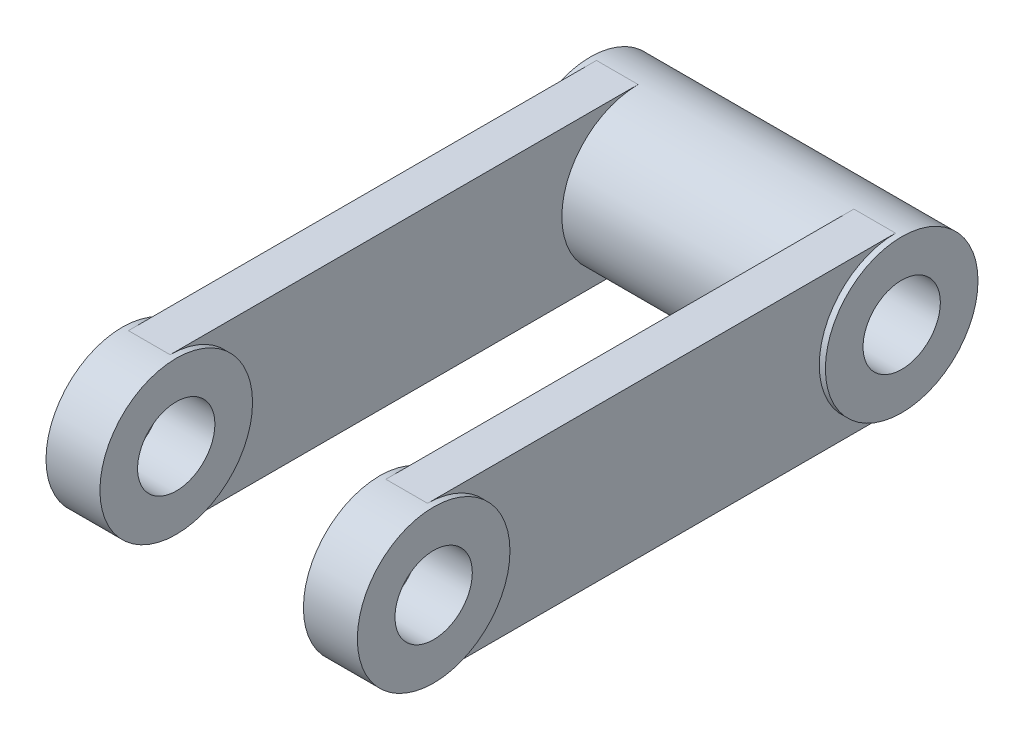
from build123d import *

# Parameters (mm, degrees)
BOSS_EXTRUDE2_START   = 100
SKETCH2_R             = 75
SKETCH2_R_2           = 38
BOSS_EXTRUDE2_DEPTH   = 53
BOSS_EXTRUDE2_2_DEPTH = 53
BOSS_EXTRUDE3_START   = 106
BOSS_EXTRUDE3_DEPTH   = 41
SKETCH2_6_R           = 75
SKETCH2_6_R_2         = 38
BOSS_EXTRUDE4_DEPTH   = 100


with BuildPart() as part:
    # Sketch2 → Boss-Extrude2 (new body)
    with BuildSketch(Plane(origin=(0, 0, 0), x_dir=(0, 0, -1), z_dir=(1, 0, 0)).offset(BOSS_EXTRUDE2_START)):
        Circle(SKETCH2_R)
        Circle(SKETCH2_R_2, mode=Mode.SUBTRACT)
    boss_extrude2 = extrude(amount=BOSS_EXTRUDE2_DEPTH)



with BuildPart() as body_2:
    # Sketch2 → Boss-Extrude2 2 (new body)
    with BuildSketch(Plane(origin=(0, 0, 0), x_dir=(0, 0, -1), z_dir=(1, 0, 0)).offset(BOSS_EXTRUDE2_START)):
        with Locations((460, 0)):
            Circle(SKETCH2_R)
        with Locations((460, 0)):
            Circle(SKETCH2_R_2, mode=Mode.SUBTRACT)
    boss_extrude2_2 = extrude(amount=BOSS_EXTRUDE2_2_DEPTH)


with BuildPart() as part_1:
    add(part.part)

    add(body_2.part)  # Boss-Extrude3 merges body 2
    # Sketch2_5 → Boss-Extrude3 (add)
    with BuildSketch(Plane(origin=(0, 0, 0), x_dir=(0, 0, -1), z_dir=(1, 0, 0)).offset(BOSS_EXTRUDE3_START)):
        with BuildLine():
            ThreePointArc((0, 75), (53.033008589, 53.033008589), (75, 0))
            Line((75, 0), (385, 0))
            ThreePointArc((385, 0), (406.966991411, 53.033008589), (460, 75))
            Line((460, 75), (0, 75))
        make_face()
        with BuildLine():
            Line((385, 0), (75, 0))
            ThreePointArc((75, 0), (53.033008589, -53.033008589), (0, -75))
            Line((0, -75), (460, -75))
            ThreePointArc((460, -75), (406.966991411, -53.033008589), (385, 0))
        make_face()
    boss_extrude3 = extrude(amount=BOSS_EXTRUDE3_DEPTH)

    # Sketch2_6 → Boss-Extrude4 (add)
    with BuildSketch(Plane(origin=(0, 0, 0), x_dir=(0, 0, -1), z_dir=(1, 0, 0))):
        with Locations((460, 0)):
            Circle(SKETCH2_6_R)
        with Locations((460, 0)):
            Circle(SKETCH2_6_R_2, mode=Mode.SUBTRACT)
    boss_extrude4 = extrude(amount=BOSS_EXTRUDE4_DEPTH)

    # Mirror1: Boss-Extrude2, Boss-Extrude2 2, Boss-Extrude3, Boss-Extrude4 across plane
    add(boss_extrude2.mirror(Plane(origin=(0, 0, 0), x_dir=(0, 0, 1), z_dir=(1, 0, 0))))
    add(boss_extrude2_2.mirror(Plane(origin=(0, 0, 0), x_dir=(0, 0, 1), z_dir=(1, 0, 0))))
    add(boss_extrude3.mirror(Plane(origin=(0, 0, 0), x_dir=(0, 0, 1), z_dir=(1, 0, 0))))
    add(boss_extrude4.mirror(Plane(origin=(0, 0, 0), x_dir=(0, 0, 1), z_dir=(1, 0, 0))))


solid = part_1.part
